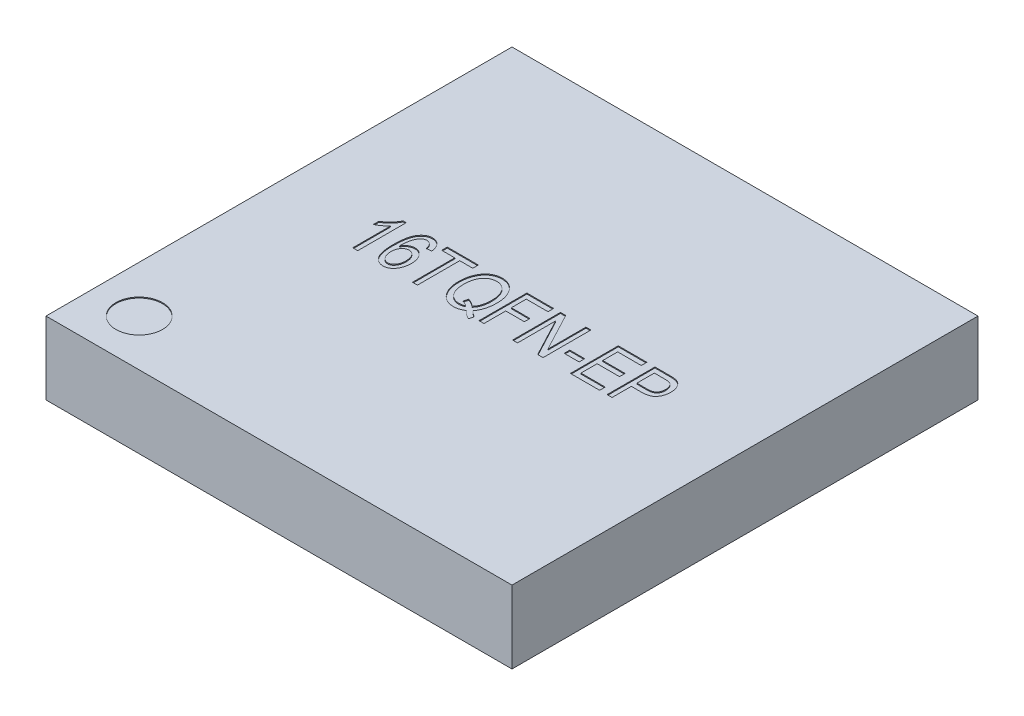
from build123d import *

# Parameters (mm, degrees)
SKETCH1_W           = 5
SKETCH1_H           = 5
BOSS_EXTRUDE1_DEPTH = 0.78
SKETCH2_R           = 0.25
CUT_EXTRUDE1_DEPTH  = 0.01
SKETCH3_W           = 0.160102983
SKETCH3_H           = 0.060038618
CUT_EXTRUDE2_DEPTH  = 0.01


with BuildPart() as part:
    # Sketch1 → Boss-Extrude1 (new body)
    with BuildSketch(Plane(origin=(0, 0, 0), x_dir=(1, 0, 0), z_dir=(0, 1, 0))):
        Rectangle(SKETCH1_W, SKETCH1_H)
    extrude(amount=BOSS_EXTRUDE1_DEPTH)

    # Sketch2 → Cut-Extrude1 (cut)
    with BuildSketch(Plane(origin=(0, 0.78, 0), x_dir=(1, 0, 0), z_dir=(0, 1, 0))):
        with Locations(Location((-2, -2, 0), (0, 0, 270))):
            Circle(SKETCH2_R)
    extrude(amount=-CUT_EXTRUDE1_DEPTH, mode=Mode.SUBTRACT)

    # Sketch3 → Cut-Extrude2 (cut)
    with BuildSketch(Plane(origin=(0, 0.78, 0), x_dir=(1, 0, 0), z_dir=(0, 1, 0))):
        with BuildLine():
            Line((-1.434901838, -0.219977705), (-1.488269499, -0.219977705))
            Line((-1.488269499, -0.219977705), (-1.488269499, 0.18695071))
            add(Edge.make_bspline(
                [(-1.488269499, 0.18695071), (-1.491547001, 0.183178024), (-1.498339623, 0.175359134), (-1.510131265, 0.164239583), (-1.523271748, 0.152773057), (-1.537820007, 0.141646477), (-1.552643525, 0.130989013), (-1.567284503, 0.121615588), (-1.581194206, 0.113460002), (-1.590525653, 0.109027064), (-1.595004821, 0.106899219)],
                knots=[0, 0, 0, 0, 0.892555828, 1.849821039, 2.893015883, 4.008277588, 5.121255548, 6.154629642, 7.114207698, 8, 8, 8, 8], degree=3))
            Line((-1.595004821, 0.106899219), (-1.595004821, 0.166937838))
            add(Edge.make_bspline(
                [(-1.595004821, 0.166937838), (-1.587806436, 0.171270099), (-1.573471306, 0.179897526), (-1.553385912, 0.194843016), (-1.534411499, 0.210974216), (-1.517115209, 0.228460143), (-1.501628281, 0.246485516), (-1.488335495, 0.264474861), (-1.477436252, 0.282237044), (-1.472089825, 0.294455376), (-1.46950743, 0.30035699)],
                knots=[0, 0, 0, 0, 1.082272232, 2.155277244, 3.222407096, 4.289527553, 5.32168536, 6.282742408, 7.170542132, 8, 8, 8, 8], degree=3))
            Line((-1.46950743, 0.30035699), (-1.434901838, 0.30035699))
            Line((-1.434901838, 0.30035699), (-1.434901838, -0.219977705))
        make_face()
        with BuildLine():
            Line((-1.03464438, 0.173608795), (-1.088012041, 0.166937838))
            add(Edge.make_bspline(
                [(-1.088012041, 0.166937838), (-1.089245631, 0.173015858), (-1.09155558, 0.184397207), (-1.096565833, 0.199815328), (-1.102148181, 0.212706363), (-1.107310515, 0.219546514), (-1.109692653, 0.222702874)],
                knots=[0, 0, 0, 0, 1.230211225, 2.30362229, 3.217213433, 4, 4, 4, 4], degree=3))
            add(Edge.make_bspline(
                [(-1.109692653, 0.222702874), (-1.11142499, 0.224652794), (-1.114793381, 0.228444259), (-1.12039166, 0.233355588), (-1.126155548, 0.237588351), (-1.132217032, 0.241073551), (-1.138647567, 0.243679285), (-1.145327444, 0.245544363), (-1.152247827, 0.246733381), (-1.156940558, 0.246903506), (-1.159307901, 0.246989329)],
                knots=[0, 0, 0, 0, 1.09495211, 2.12904747, 3.12182315, 4.09596367, 5.058329339, 6.028853599, 7.005615717, 8, 8, 8, 8], degree=3))
            add(Edge.make_bspline(
                [(-1.159307901, 0.246989329), (-1.162975302, 0.246853258), (-1.170241161, 0.246583673), (-1.180785449, 0.243677281), (-1.190823596, 0.239313189), (-1.2002152, 0.233001478), (-1.208978173, 0.224965368), (-1.217299006, 0.215280661), (-1.224864749, 0.203725046), (-1.229256793, 0.195228105), (-1.231541864, 0.190807358)],
                knots=[0, 0, 0, 0, 0.906800098, 1.796553483, 2.691003266, 3.610512055, 4.585978966, 5.630213089, 6.767058994, 8, 8, 8, 8], degree=3))
            add(Edge.make_bspline(
                [(-1.231541864, 0.190807358), (-1.233459688, 0.186564093), (-1.237446887, 0.177742254), (-1.242122479, 0.163366121), (-1.246231218, 0.147609729), (-1.249312017, 0.130335498), (-1.252112963, 0.111722411), (-1.253898811, 0.091604797), (-1.255065988, 0.070083933), (-1.25522518, 0.055235742), (-1.25530715, 0.047590236)],
                knots=[0, 0, 0, 0, 0.763508889, 1.587351645, 2.476402758, 3.433472996, 4.464603951, 5.563935012, 6.745641893, 8, 8, 8, 8], degree=3))
            add(Edge.make_bspline(
                [(-1.25530715, 0.047590236), (-1.252285411, 0.052792759), (-1.246405696, 0.062915853), (-1.235449248, 0.076179647), (-1.223701637, 0.087739111), (-1.210656554, 0.09702737), (-1.196886651, 0.104314823), (-1.182660123, 0.109715359), (-1.167967207, 0.112973623), (-1.158038301, 0.113370793), (-1.153053878, 0.113570177)],
                knots=[0, 0, 0, 0, 1.127907175, 2.194687167, 3.21896757, 4.214740698, 5.189497801, 6.137088422, 7.064797308, 8, 8, 8, 8], degree=3))
            add(Edge.make_bspline(
                [(-1.153053878, 0.113570177), (-1.148910618, 0.113426051), (-1.140744518, 0.113141989), (-1.128694155, 0.110992269), (-1.117093824, 0.107417361), (-1.105835854, 0.102500849), (-1.095032145, 0.096035219), (-1.084606009, 0.088224418), (-1.074688274, 0.078906965), (-1.065105286, 0.068489112), (-1.056405978, 0.056753946), (-1.048775984, 0.043969578), (-1.042265173, 0.030269924), (-1.037097616, 0.015533693), (-1.032907491, -6.3937e-05), (-1.029998927, -0.016665041), (-1.02836927, -0.034200258), (-1.028107476, -0.046216745), (-1.027973423, -0.052369894)],
                knots=[0, 0, 0, 0, 0.860357646, 1.695709716, 2.533583491, 3.377064945, 4.241047709, 5.143225219, 6.077846286, 7.063889573, 8.080111547, 9.106229702, 10.152257742, 11.225204373, 12.345649275, 13.503769734, 14.721782881, 16, 16, 16, 16], degree=3))
            add(Edge.make_bspline(
                [(-1.027973423, -0.052369894), (-1.028186226, -0.060720186), (-1.028603086, -0.077077508), (-1.03209694, -0.101027035), (-1.037979115, -0.123745603), (-1.04464625, -0.141750976), (-1.051050711, -0.155247367), (-1.056178777, -0.164670973), (-1.061577621, -0.173424874), (-1.067293778, -0.181524081), (-1.073501041, -0.188779687), (-1.079859103, -0.195546223), (-1.086623014, -0.201583209), (-1.095997738, -0.208589784), (-1.108329164, -0.215829988), (-1.124081964, -0.222029768), (-1.140563658, -0.225948587), (-1.151851066, -0.226414172), (-1.157535928, -0.226648662)],
                knots=[0, 0, 0, 0, 1.657459496, 3.246784879, 4.79287916, 6.310074839, 7.050696599, 7.757650882, 8.439205885, 9.092012499, 9.723586031, 10.333538589, 10.934530017, 11.52093132, 12.655638276, 13.761218907, 14.872446044, 16, 16, 16, 16], degree=3))
            add(Edge.make_bspline(
                [(-1.157535928, -0.226648662), (-1.162656559, -0.226469708), (-1.172728099, -0.22611773), (-1.187465441, -0.223288439), (-1.201561404, -0.218860956), (-1.214858881, -0.212342449), (-1.227648741, -0.204324142), (-1.239486067, -0.194177686), (-1.250729778, -0.182378045), (-1.26133877, -0.168796536), (-1.270879904, -0.152968238), (-1.279204604, -0.134834632), (-1.286159532, -0.114251014), (-1.291639549, -0.091266468), (-1.296134495, -0.065933228), (-1.299294559, -0.038226634), (-1.301154771, -0.008096397), (-1.301370566, 0.012773387), (-1.301482685, 0.023616482)],
                knots=[0, 0, 0, 0, 0.760819453, 1.496421576, 2.223429687, 2.951263266, 3.692179274, 4.462099387, 5.262291211, 6.1127328, 7.019077074, 8.003719522, 9.073773746, 10.244022616, 11.513769144, 12.897217303, 14.387919526, 16, 16, 16, 16], degree=3))
            add(Edge.make_bspline(
                [(-1.301482685, 0.023616482), (-1.301383999, 0.035641451), (-1.301193895, 0.05880569), (-1.299153261, 0.092223491), (-1.296065568, 0.122962442), (-1.291467039, 0.151010651), (-1.285761022, 0.176413332), (-1.278581225, 0.199115786), (-1.270247621, 0.219217283), (-1.2603331, 0.23658824), (-1.249402746, 0.251581841), (-1.237819951, 0.264588373), (-1.225553354, 0.275703571), (-1.212470025, 0.284766922), (-1.198535535, 0.291680098), (-1.183955744, 0.296774604), (-1.168563609, 0.29972435), (-1.158069367, 0.300143949), (-1.152741177, 0.30035699)],
                knots=[0, 0, 0, 0, 1.648816343, 3.176189159, 4.589499976, 5.883521052, 7.071677735, 8.156616623, 9.145117633, 10.049911772, 10.892392766, 11.685345428, 12.434380955, 13.15730553, 13.86047472, 14.561137348, 15.269453316, 16, 16, 16, 16], degree=3))
            add(Edge.make_bspline(
                [(-1.152741177, 0.30035699), (-1.14888102, 0.300246848), (-1.141271897, 0.300029737), (-1.130074833, 0.298611998), (-1.119415783, 0.295944525), (-1.109195728, 0.292412459), (-1.099512071, 0.287784947), (-1.090215916, 0.282270026), (-1.081592398, 0.275488872), (-1.073337719, 0.267914181), (-1.065700222, 0.259368294), (-1.058910725, 0.249792449), (-1.052889698, 0.239337395), (-1.04750197, 0.228006667), (-1.043074785, 0.215702283), (-1.039455394, 0.202483825), (-1.036480306, 0.188393888), (-1.035267076, 0.178623497), (-1.03464438, 0.173608795)],
                knots=[0, 0, 0, 0, 0.965625992, 1.903437499, 2.816107718, 3.709373219, 4.603483816, 5.496241877, 6.407089735, 7.341876361, 8.295975248, 9.267838192, 10.27248647, 11.310449055, 12.401896837, 13.538363143, 14.736552469, 16, 16, 16, 16], degree=3))
        make_face()
        with BuildLine():
            add(Edge.make_bspline(
                [(-1.248115024, -0.050389454), (-1.248038825, -0.054909113), (-1.247890223, -0.063723335), (-1.246620573, -0.076614317), (-1.244524809, -0.088794491), (-1.241775751, -0.100372385), (-1.237971606, -0.111183145), (-1.233519893, -0.121425089), (-1.228065876, -0.130879852), (-1.221936181, -0.139645044), (-1.215240477, -0.147474755), (-1.208175807, -0.154328243), (-1.200935219, -0.160211263), (-1.193305825, -0.164932101), (-1.185490026, -0.168780158), (-1.177292701, -0.171342635), (-1.168894, -0.172988223), (-1.163206947, -0.173183107), (-1.160350238, -0.173281001)],
                knots=[0, 0, 0, 0, 1.295936842, 2.527331243, 3.710032566, 4.838610101, 5.935196688, 6.992417297, 8.036740745, 9.059547266, 10.056000021, 10.986130286, 11.879343137, 12.725347321, 13.554280309, 14.370418864, 15.181432095, 16, 16, 16, 16], degree=3))
            add(Edge.make_bspline(
                [(-1.160350238, -0.173281001), (-1.157807976, -0.173171469), (-1.152751383, -0.172953607), (-1.145294226, -0.17148848), (-1.138118504, -0.168887365), (-1.131076894, -0.165465355), (-1.124314171, -0.16089994), (-1.117678026, -0.155489126), (-1.111474209, -0.148889963), (-1.105280021, -0.141594955), (-1.099740285, -0.133234588), (-1.094643044, -0.124213035), (-1.090676678, -0.114276182), (-1.087149977, -0.103761463), (-1.08464434, -0.092392922), (-1.082580873, -0.080370757), (-1.081630996, -0.067533447), (-1.081439654, -0.058763819), (-1.081341084, -0.054246101)],
                knots=[0, 0, 0, 0, 0.772594522, 1.536700729, 2.298102904, 3.086693685, 3.909598938, 4.772126543, 5.683120767, 6.657848237, 7.676972593, 8.726121203, 9.800678132, 10.92259173, 12.09308983, 13.334225679, 14.626713094, 16, 16, 16, 16], degree=3))
            add(Edge.make_bspline(
                [(-1.081341084, -0.054246101), (-1.081435994, -0.049832016), (-1.081620105, -0.041269377), (-1.082618115, -0.028756906), (-1.084507157, -0.01702454), (-1.087039113, -0.006009093), (-1.090561337, 0.004127774), (-1.094566905, 0.013612133), (-1.099506861, 0.022289189), (-1.105129787, 0.030185737), (-1.111221941, 0.037257665), (-1.117779066, 0.043377033), (-1.124595904, 0.048599676), (-1.1318257, 0.052818834), (-1.139308437, 0.056222086), (-1.147258262, 0.058457231), (-1.155458916, 0.060022354), (-1.161072363, 0.060142247), (-1.163894184, 0.060202516)],
                knots=[0, 0, 0, 0, 1.343777819, 2.606719898, 3.816838752, 4.958326899, 6.041908764, 7.079242616, 8.08798765, 9.073968097, 10.026073332, 10.923948235, 11.799625043, 12.633965371, 13.467232591, 14.293828985, 15.142325764, 16, 16, 16, 16], degree=3))
            add(Edge.make_bspline(
                [(-1.163894184, 0.060202516), (-1.166681754, 0.060144739), (-1.172192944, 0.060030511), (-1.180251205, 0.058444213), (-1.188094426, 0.056208192), (-1.195589207, 0.052771741), (-1.202930538, 0.048624398), (-1.209985483, 0.043472344), (-1.21660027, 0.037233683), (-1.223081559, 0.030318614), (-1.228984986, 0.022554251), (-1.23412163, 0.014064308), (-1.238387127, 0.004923004), (-1.241948598, -0.004839998), (-1.244774867, -0.015295108), (-1.246711567, -0.026425401), (-1.24786739, -0.03820441), (-1.248030943, -0.046252158), (-1.248115024, -0.050389454)],
                knots=[0, 0, 0, 0, 0.863470541, 1.707132358, 2.539352989, 3.38871181, 4.257816365, 5.15261427, 6.090962397, 7.075009843, 8.09049846, 9.111009759, 10.147788812, 11.215218178, 12.331811356, 13.503305971, 14.716465586, 16, 16, 16, 16], degree=3))
        make_face(mode=Mode.SUBTRACT)
        Polygon((-0.847857567, -0.219977705), (-0.847857567, 0.233647414), (-0.987947677, 0.233647414), (-0.987947677, 0.293686032), (-0.654399796, 0.293686032), (-0.654399796, 0.233647414), (-0.794489906, 0.233647414), (-0.794489906, -0.219977705), align=None)
        with BuildLine():
            add(Edge.make_bspline(
                [(-0.259979426, -0.161085657), (-0.254272723, -0.166366951), (-0.243359556, -0.176466591), (-0.226740007, -0.189864035), (-0.210844491, -0.201032942), (-0.200127291, -0.207094819), (-0.195041823, -0.209971268)],
                knots=[0, 0, 0, 0, 1.144319735, 2.188330579, 3.140336391, 4, 4, 4, 4], degree=3))
            Line((-0.195041823, -0.209971268), (-0.208487972, -0.26000345))
            add(Edge.make_bspline(
                [(-0.208487972, -0.26000345), (-0.216087042, -0.256098523), (-0.231656953, -0.248097627), (-0.253837097, -0.23264826), (-0.27595995, -0.214652308), (-0.289771156, -0.200825726), (-0.296878161, -0.193710809)],
                knots=[0, 0, 0, 0, 0.922267723, 1.889655912, 2.914053896, 4, 4, 4, 4], degree=3))
            add(Edge.make_bspline(
                [(-0.296878161, -0.193710809), (-0.300870728, -0.196344281), (-0.308758509, -0.201547012), (-0.32119005, -0.208221177), (-0.333859991, -0.214019713), (-0.346980003, -0.218545491), (-0.360289724, -0.222277116), (-0.373977488, -0.224710896), (-0.387937859, -0.226363515), (-0.397389309, -0.226553089), (-0.402154211, -0.226648662)],
                knots=[0, 0, 0, 0, 1.023953822, 2.022940087, 3.018844809, 4.005026068, 4.992554187, 5.976345858, 6.979784929, 8, 8, 8, 8], degree=3))
            add(Edge.make_bspline(
                [(-0.402154211, -0.226648662), (-0.409848601, -0.226416894), (-0.424984413, -0.225960977), (-0.447074421, -0.222111661), (-0.468076894, -0.215860731), (-0.487855807, -0.206893932), (-0.506583037, -0.195567826), (-0.524099095, -0.181615924), (-0.540558427, -0.165253492), (-0.550165168, -0.152760652), (-0.555065067, -0.146388703)],
                knots=[0, 0, 0, 0, 1.026617298, 2.019482628, 2.983586709, 3.944841198, 4.910584164, 5.897973493, 6.927865462, 8, 8, 8, 8], degree=3))
            add(Edge.make_bspline(
                [(-0.555065067, -0.146388703), (-0.559277846, -0.140240152), (-0.567737362, -0.127893488), (-0.578454777, -0.107946606), (-0.587556378, -0.086812959), (-0.594931142, -0.064445759), (-0.600672189, -0.040917345), (-0.60466735, -0.016205006), (-0.607255329, 0.009663617), (-0.6075519, 0.027327766), (-0.607703092, 0.036332995)],
                knots=[0, 0, 0, 0, 0.924595461, 1.856643742, 2.805148767, 3.777510999, 4.776413242, 5.807987904, 6.882506607, 8, 8, 8, 8], degree=3))
            add(Edge.make_bspline(
                [(-0.607703092, 0.036332995), (-0.60763569, 0.043110707), (-0.607503164, 0.056437054), (-0.606080614, 0.0760867), (-0.603918996, 0.095044139), (-0.600940387, 0.113327094), (-0.596938176, 0.130885657), (-0.592169174, 0.147771432), (-0.586542407, 0.164010668), (-0.579986499, 0.179485064), (-0.572684157, 0.194138407), (-0.564916808, 0.207925212), (-0.556494047, 0.220689149), (-0.547711762, 0.23263202), (-0.538155023, 0.243469241), (-0.528182008, 0.253428381), (-0.51755444, 0.262303165), (-0.506515762, 0.270369682), (-0.49497535, 0.27744316), (-0.482989502, 0.283505643), (-0.470706628, 0.28872026), (-0.458047234, 0.293065113), (-0.444975418, 0.296208014), (-0.43162676, 0.298685777), (-0.417885213, 0.300007086), (-0.408619133, 0.300239354), (-0.403926184, 0.30035699)],
                knots=[0, 0, 0, 0, 1.306147432, 2.568149072, 3.795050195, 4.982969685, 6.136450494, 7.264217415, 8.363408239, 9.446756523, 10.500962933, 11.517661666, 12.494657841, 13.446944177, 14.37238534, 15.276847829, 16.160873942, 17.038254774, 17.909994876, 18.76655507, 19.624789052, 20.480353886, 21.342810126, 22.213726715, 23.09531441, 24, 24, 24, 24], degree=3))
            add(Edge.make_bspline(
                [(-0.403926184, 0.30035699), (-0.399301538, 0.300249337), (-0.390099084, 0.30003512), (-0.376475875, 0.298549212), (-0.363141386, 0.296126412), (-0.350115369, 0.292846697), (-0.337453572, 0.288410323), (-0.325106099, 0.283048346), (-0.312988933, 0.276853371), (-0.301360773, 0.269481921), (-0.29005609, 0.261416239), (-0.279400886, 0.252265172), (-0.269296676, 0.242270679), (-0.259799603, 0.231392918), (-0.250889425, 0.219675747), (-0.242667014, 0.20699301), (-0.23496372, 0.193460826), (-0.227882823, 0.179091872), (-0.22154007, 0.163942853), (-0.215877284, 0.148137232), (-0.211220483, 0.131581319), (-0.207331652, 0.114402006), (-0.204490592, 0.096494367), (-0.202248817, 0.077969824), (-0.201013179, 0.058725501), (-0.200855111, 0.045680912), (-0.200774677, 0.039043072)],
                knots=[0, 0, 0, 0, 0.899113153, 1.789120031, 2.661021602, 3.532687604, 4.397942666, 5.266356563, 6.148612572, 7.040847191, 7.940822803, 8.846485162, 9.768428376, 10.701980572, 11.651816038, 12.628023396, 13.638548851, 14.677839001, 15.740533752, 16.830240592, 17.940052621, 19.082387632, 20.252958034, 21.463772495, 22.709420938, 24, 24, 24, 24], degree=3))
            add(Edge.make_bspline(
                [(-0.200774677, 0.039043072), (-0.200939894, 0.028751689), (-0.201263214, 0.008612018), (-0.204224886, -0.020831264), (-0.209113244, -0.048770948), (-0.215819392, -0.075103509), (-0.224344196, -0.09961669), (-0.234470053, -0.122177758), (-0.246151402, -0.142754601), (-0.255434335, -0.155060477), (-0.259979426, -0.161085657)],
                knots=[0, 0, 0, 0, 1.161385065, 2.272766848, 3.335983156, 4.360417864, 5.336532936, 6.261559089, 7.148827914, 8, 8, 8, 8], degree=3))
        make_face()
        with BuildLine():
            add(Edge.make_bspline(
                [(-0.388291127, -0.075926713), (-0.380216462, -0.07868004), (-0.364424763, -0.084064748), (-0.342580534, -0.095372455), (-0.322554991, -0.108249393), (-0.311025663, -0.118771997), (-0.305321091, -0.123978455)],
                knots=[0, 0, 0, 0, 1.056839212, 2.066870382, 3.043510774, 4, 4, 4, 4], degree=3))
            add(Edge.make_bspline(
                [(-0.305321091, -0.123978455), (-0.301204034, -0.119278458), (-0.292878625, -0.109774241), (-0.282457714, -0.093513265), (-0.273738003, -0.07559866), (-0.266535642, -0.056075687), (-0.260905778, -0.034933152), (-0.257040099, -0.012112231), (-0.25460278, 0.012341155), (-0.25429895, 0.029204293), (-0.254142338, 0.037896501)],
                knots=[0, 0, 0, 0, 0.861668404, 1.742444334, 2.656310883, 3.607919593, 4.61088855, 5.672348466, 6.800197759, 8, 8, 8, 8], degree=3))
            add(Edge.make_bspline(
                [(-0.254142338, 0.037896501), (-0.254196219, 0.043214268), (-0.254301954, 0.053649846), (-0.255313787, 0.068977839), (-0.256665559, 0.083709685), (-0.258937807, 0.097775955), (-0.261566867, 0.111306683), (-0.265041363, 0.124158894), (-0.268990439, 0.136459985), (-0.273587373, 0.148105822), (-0.278658071, 0.159162344), (-0.284298856, 0.169486009), (-0.290379784, 0.179111682), (-0.296806406, 0.188126653), (-0.303845882, 0.196393379), (-0.311332708, 0.203990597), (-0.319279043, 0.210939936), (-0.330456735, 0.218994506), (-0.345065726, 0.227580966), (-0.363728747, 0.23493013), (-0.383241482, 0.239506563), (-0.396570298, 0.240045986), (-0.403300781, 0.240318371)],
                knots=[0, 0, 0, 0, 1.132669229, 2.222748241, 3.271511854, 4.282750905, 5.256763404, 6.206512894, 7.117035469, 8.007696564, 8.872042555, 9.706723573, 10.511701292, 11.296415213, 12.063119802, 12.822032001, 13.567065486, 14.308782618, 15.754757786, 17.163580597, 18.567729262, 20, 20, 20, 20], degree=3))
            add(Edge.make_bspline(
                [(-0.403300781, 0.240318371), (-0.408626373, 0.240158223), (-0.419089557, 0.239843579), (-0.434429274, 0.237355603), (-0.449105106, 0.233439988), (-0.46308284, 0.227776169), (-0.476250457, 0.220358249), (-0.488877763, 0.211598336), (-0.500695529, 0.201066758), (-0.511726847, 0.188946937), (-0.521884323, 0.175357596), (-0.530563224, 0.160019694), (-0.537938726, 0.143215464), (-0.543979199, 0.124853047), (-0.54864845, 0.10496994), (-0.551886673, 0.083531001), (-0.554066582, 0.060560114), (-0.554243978, 0.044711838), (-0.554335431, 0.036541463)],
                knots=[0, 0, 0, 0, 0.895504286, 1.75939617, 2.607301794, 3.446316705, 4.288805896, 5.144971447, 6.026944565, 6.945407222, 7.898157637, 8.874707462, 9.90319225, 10.980779795, 12.122049517, 13.334781701, 14.625980997, 16, 16, 16, 16], degree=3))
            add(Edge.make_bspline(
                [(-0.554335431, 0.036541463), (-0.554181829, 0.028477425), (-0.553883411, 0.012810707), (-0.551971439, -0.009947052), (-0.548481452, -0.031177057), (-0.543911126, -0.05095789), (-0.537729542, -0.069203878), (-0.530198631, -0.085942415), (-0.521492298, -0.101319261), (-0.511214682, -0.114974358), (-0.499935861, -0.12698301), (-0.488159572, -0.137683079), (-0.475548906, -0.146552494), (-0.462377486, -0.153944843), (-0.448494604, -0.1595788), (-0.434001898, -0.163696834), (-0.418842967, -0.166111906), (-0.408520899, -0.166442735), (-0.403300781, -0.166610044)],
                knots=[0, 0, 0, 0, 1.362122616, 2.646315827, 3.853269332, 4.993430095, 6.071662911, 7.101321269, 8.089818823, 9.049913911, 9.980037034, 10.869465697, 11.732461496, 12.578347019, 13.415309708, 14.256888884, 15.118466808, 16, 16, 16, 16], degree=3))
            add(Edge.make_bspline(
                [(-0.403300781, -0.166610044), (-0.398252415, -0.166450492), (-0.38819763, -0.166132714), (-0.373290738, -0.163540622), (-0.358738707, -0.159297478), (-0.34947643, -0.15521419), (-0.344825668, -0.153163895)],
                knots=[0, 0, 0, 0, 1.000987373, 1.993657566, 2.992578082, 4, 4, 4, 4], degree=3))
            add(Edge.make_bspline(
                [(-0.344825668, -0.153163895), (-0.34936067, -0.149958164), (-0.358331965, -0.143616478), (-0.372571008, -0.135558691), (-0.387308929, -0.129014636), (-0.397498032, -0.125861226), (-0.402571145, -0.124291156)],
                knots=[0, 0, 0, 0, 1.026066201, 2.029799427, 3.019045021, 4, 4, 4, 4], degree=3))
            Line((-0.402571145, -0.124291156), (-0.388291127, -0.075926713))
        make_face(mode=Mode.SUBTRACT)
        Polygon((-0.134065101, -0.219977705), (-0.134065101, 0.293686032), (0.152786077, 0.293686032), (0.152786077, 0.233647414), (-0.08069744, 0.233647414), (-0.08069744, 0.073544431), (0.119431289, 0.073544431), (0.119431289, 0.013505812), (-0.08069744, 0.013505812), (-0.08069744, -0.219977705), align=None)
        Polygon((0.226166611, -0.219977705), (0.226166611, 0.293686032), (0.282973984, 0.293686032), (0.499675873, -0.115743992), (0.499675873, 0.293686032), (0.553043534, 0.293686032), (0.553043534, -0.219977705), (0.495923459, -0.219977705), (0.279534272, 0.188931151), (0.279534272, -0.219977705), align=None)
        with Locations((0.70647556, -0.03652637)):
            Rectangle(SKETCH3_W, SKETCH3_H)
        Polygon((0.84656567, -0.219977705), (0.84656567, 0.293686032), (1.15342972, 0.293686032), (1.15342972, 0.233647414), (0.89993333, 0.233647414), (0.89993333, 0.073544431), (1.140087805, 0.073544431), (1.140087805, 0.013505812), (0.89993333, 0.013505812), (0.89993333, -0.159939086), (1.160100678, -0.159939086), (1.160100678, -0.219977705), align=None)
        with BuildLine():
            Line((1.240152169, -0.219977705), (1.240152169, 0.293686032))
            Line((1.240152169, 0.293686032), (1.398378945, 0.293686032))
            add(Edge.make_bspline(
                [(1.398378945, 0.293686032), (1.402896696, 0.293690272), (1.411588174, 0.293698428), (1.424163958, 0.293083165), (1.435855801, 0.292461458), (1.446622688, 0.291261836), (1.456472768, 0.289951892), (1.465395979, 0.28831496), (1.473394103, 0.286246154), (1.478369196, 0.28457478), (1.480723579, 0.28378383)],
                knots=[0, 0, 0, 0, 1.301145482, 2.503209419, 3.626350361, 4.67304202, 5.622796861, 6.488461115, 7.284688674, 8, 8, 8, 8], degree=3))
            add(Edge.make_bspline(
                [(1.480723579, 0.28378383), (1.483704827, 0.282629924), (1.48966026, 0.280324847), (1.498048828, 0.275774155), (1.506050947, 0.270647342), (1.513575929, 0.264810844), (1.520579639, 0.258174701), (1.527171706, 0.250884723), (1.533221164, 0.242791048), (1.538794904, 0.234066061), (1.543984918, 0.224797787), (1.548270122, 0.214872891), (1.55211951, 0.204500622), (1.555048307, 0.193559498), (1.557523419, 0.18212691), (1.559099869, 0.170168209), (1.560223469, 0.157682477), (1.560312564, 0.14918609), (1.560358135, 0.14484029)],
                knots=[0, 0, 0, 0, 0.897158766, 1.79219156, 2.674738776, 3.564969572, 4.462552928, 5.381685756, 6.322532571, 7.297145314, 8.28871417, 9.302465757, 10.330585605, 11.393732126, 12.480975679, 13.614163778, 14.779673607, 16, 16, 16, 16], degree=3))
            add(Edge.make_bspline(
                [(1.560358135, 0.14484029), (1.5602699, 0.139138078), (1.560097332, 0.127985888), (1.558402984, 0.111674448), (1.555587032, 0.096208886), (1.551744965, 0.081514905), (1.546755133, 0.067614695), (1.540576323, 0.054544783), (1.533327853, 0.042258361), (1.525052681, 0.030732506), (1.515301185, 0.020241198), (1.503792515, 0.01126596), (1.490771475, 0.003589774), (1.476075516, -0.002511593), (1.459854548, -0.007439847), (1.441961512, -0.010799506), (1.422465544, -0.012745371), (1.408945952, -0.013030106), (1.401922892, -0.013178018)],
                knots=[0, 0, 0, 0, 1.066125632, 2.085091685, 3.062630143, 4.003547869, 4.922307223, 5.820454748, 6.703048758, 7.586837887, 8.469431897, 9.371589709, 10.306565591, 11.287746888, 12.340181319, 13.471797101, 14.68666727, 16, 16, 16, 16], degree=3))
            Line((1.401922892, -0.013178018), (1.29351983, -0.013178018))
            Line((1.29351983, -0.013178018), (1.29351983, -0.219977705))
            Line((1.29351983, -0.219977705), (1.240152169, -0.219977705))
        make_face()
        with BuildLine():
            Line((1.29351983, 0.0468606), (1.40525837, 0.0468606))
            add(Edge.make_bspline(
                [(1.40525837, 0.0468606), (1.40949879, 0.046955869), (1.417714649, 0.047140453), (1.429639624, 0.048124986), (1.440685617, 0.050002711), (1.450849051, 0.05257414), (1.460101631, 0.055927291), (1.468489516, 0.059959326), (1.475964814, 0.064812338), (1.482645284, 0.070359312), (1.488339075, 0.076804278), (1.493460895, 0.083824763), (1.497614565, 0.091752261), (1.501008987, 0.100398664), (1.503766196, 0.10973578), (1.505585422, 0.119836092), (1.506748254, 0.130672097), (1.50690813, 0.138166153), (1.506990474, 0.14202598)],
                knots=[0, 0, 0, 0, 1.269306236, 2.459294321, 3.577321076, 4.618943517, 5.592639886, 6.518111891, 7.397820391, 8.253919533, 9.107995395, 9.965041305, 10.848919063, 11.777714976, 12.741869721, 13.757527659, 14.845010431, 16, 16, 16, 16], degree=3))
            add(Edge.make_bspline(
                [(1.506990474, 0.14202598), (1.506871924, 0.147039611), (1.506642522, 0.156741274), (1.504269655, 0.170696148), (1.500599076, 0.183569193), (1.495226945, 0.195101469), (1.488944301, 0.205214147), (1.482064848, 0.213864811), (1.474381362, 0.220661177), (1.467230576, 0.224897178), (1.46095062, 0.227568734), (1.455354325, 0.229217373), (1.448892209, 0.230512336), (1.441587597, 0.231646323), (1.433454717, 0.232602496), (1.424478051, 0.233165849), (1.414644161, 0.233628142), (1.407795395, 0.233640799), (1.404216033, 0.233647414)],
                knots=[0, 0, 0, 0, 1.500314686, 2.903195123, 4.226916567, 5.498136997, 6.699407891, 7.786731959, 8.797026544, 9.75363827, 10.261964553, 10.838097333, 11.497334866, 12.234733717, 13.051831226, 13.948971176, 14.928073425, 16, 16, 16, 16], degree=3))
            Line((1.404216033, 0.233647414), (1.29351983, 0.233647414))
            Line((1.29351983, 0.233647414), (1.29351983, 0.0468606))
        make_face(mode=Mode.SUBTRACT)
    extrude(amount=-CUT_EXTRUDE2_DEPTH, mode=Mode.SUBTRACT)


solid = part.part
